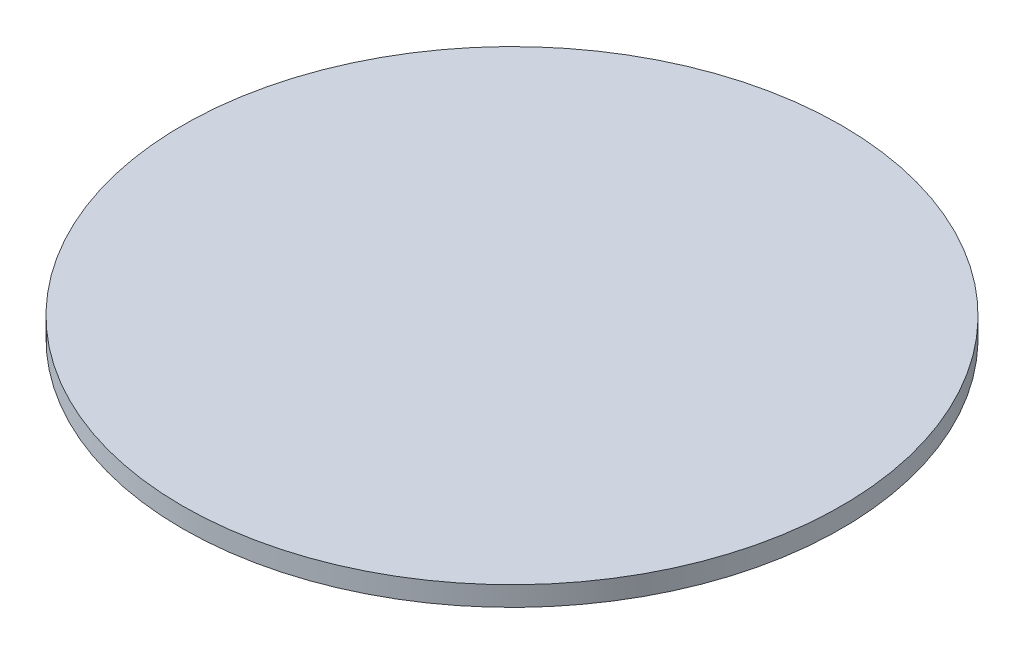
from build123d import *

# Parameters (mm, degrees)
SKETCH1_R           = 33.51
BOSS_EXTRUDE1_DEPTH = 2


with BuildPart() as part:
    # Sketch1 → Boss-Extrude1 (new body)
    with BuildSketch(Plane(origin=(0, 0, 0), x_dir=(1, 0, 0), z_dir=(0, 1, 0))):
        Circle(SKETCH1_R)
    extrude(amount=BOSS_EXTRUDE1_DEPTH)


solid = part.part
